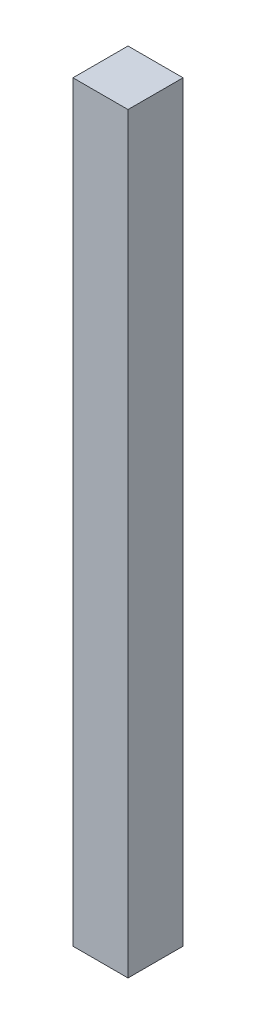
from build123d import *

# Parameters (mm, degrees)
SKETCH1_W           = 38.1
SKETCH1_H           = 38.1
BOSS_EXTRUDE1_DEPTH = 520.7


with BuildPart() as part:
    # Sketch1 → Boss-Extrude1 (new body)
    with BuildSketch(Plane(origin=(0, 0, 0), x_dir=(1, 0, 0), z_dir=(0, 1, 0))):
        with Locations((19.05, -19.05)):
            Rectangle(SKETCH1_W, SKETCH1_H)
    extrude(amount=BOSS_EXTRUDE1_DEPTH)


solid = part.part
